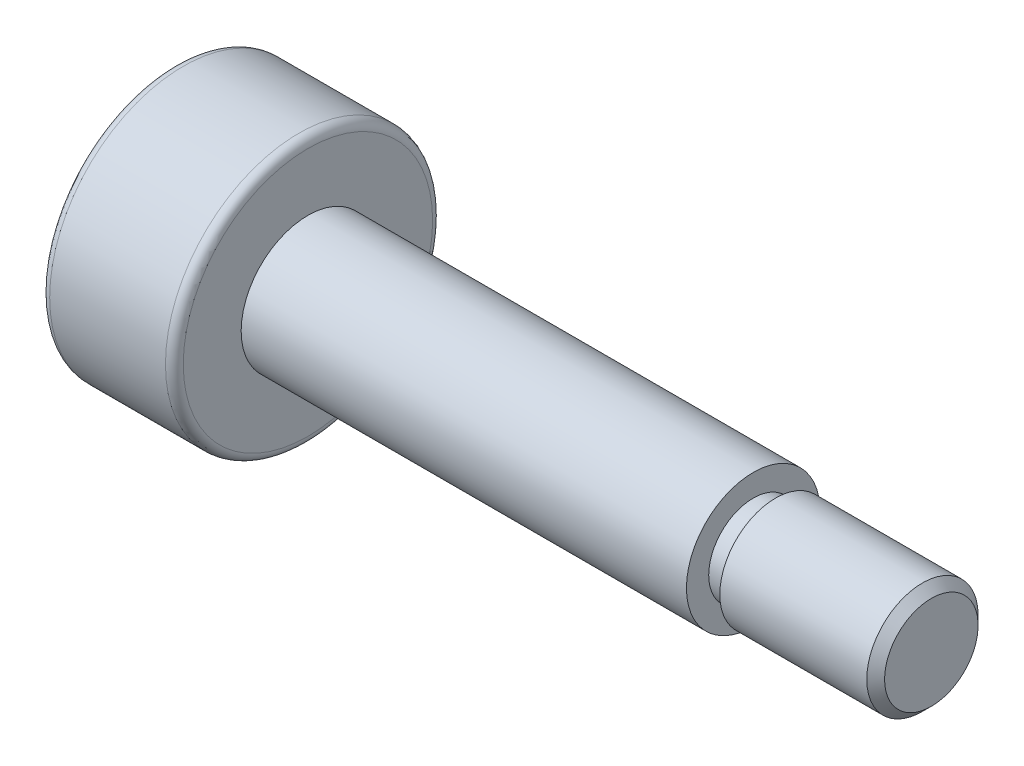
from build123d import *

# Parameters (mm, degrees)
FILLET_1_R          = 0.2
CHAMFER_1_SIZE      = 0.2
SKETCH_3_W          = 0.5
SKETCH_3_H          = 0.25
CUT_EXTRUDE_1_DEPTH = 2


with BuildPart() as part:
    # 草图1 → 旋转1 (revolve)
    with BuildSketch(Plane.XY):
        Polygon((-8.5, 0), (-8.5, 3), (-5.5, 3), (-5.5, 1.5), (4.5, 1.5), (4.5, 1.25), (8.5, 1.25), (8.5, 0), align=None)
    revolve(axis=Axis((-8.5, 0, 0), (1, 0, 0)))

    # 圆角1
    fillet_1_edges = [part.edges().sort_by_distance(p)[0] for p in [
        (-5.5, -3, 0),
        (-8.5, -3, 0),
    ]]
    fillet(fillet_1_edges, radius=FILLET_1_R)

    # 倒角1
    chamfer_1_edges = [part.edges().sort_by_distance(p)[0] for p in [
        (8.5, -1.25, 0),
    ]]
    chamfer(chamfer_1_edges, length=CHAMFER_1_SIZE)

    # 草图3 → 切除-旋转1 (revolve, cut)
    with BuildSketch(Plane.XY):
        with Locations((4.75, 1.125)):
            Rectangle(SKETCH_3_W, SKETCH_3_H)
    revolve(axis=Axis((4.5, 0, 0), (1, 0, 0)), mode=Mode.SUBTRACT)

    # 草图4 → 切除-拉伸1 (cut)
    with BuildSketch(Plane.ZY.offset(8.5)):
        Polygon((1.732050808, 0), (0.866025404, 1.5), (-0.866025404, 1.5), (-1.732050808, 0), (-0.866025404, -1.5), (0.866025404, -1.5), align=None)
    extrude(amount=-CUT_EXTRUDE_1_DEPTH, mode=Mode.SUBTRACT)


solid = part.part
